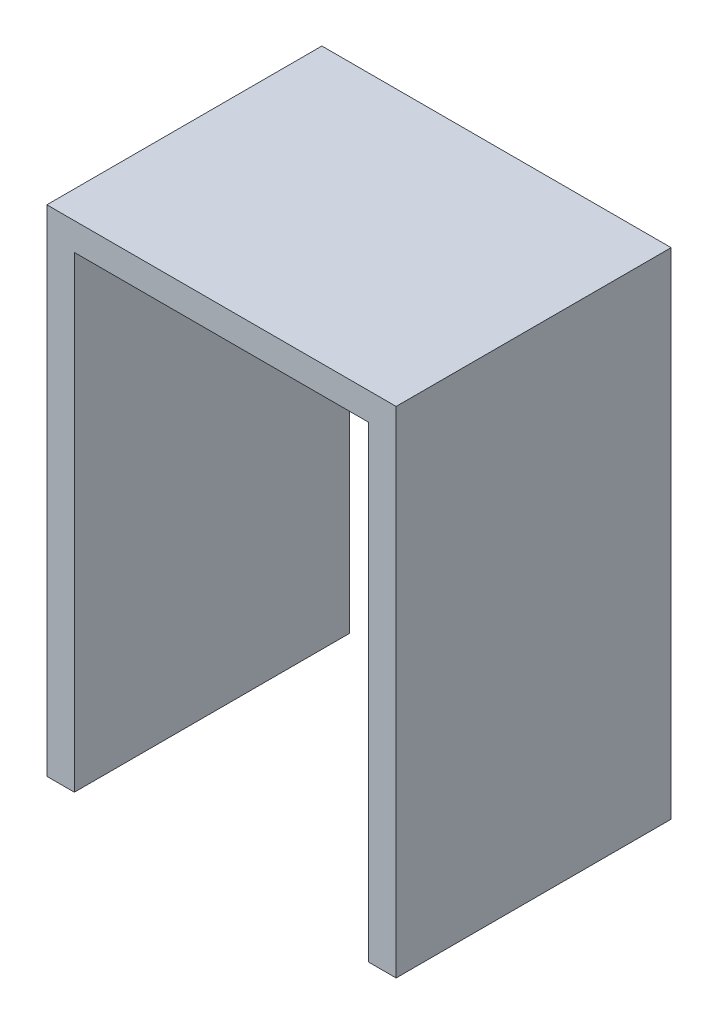
from build123d import *

# Parameters (mm, degrees)
BOSS_EXTRUDE1_DEPTH = 10


with BuildPart() as part:
    # Sketch1 → Boss-Extrude1 (new body)
    with BuildSketch(Plane.XY):
        Polygon((-2.333333333, 0), (-2.333333333, 17), (8.366666667, 17), (8.366666667, 0), (9.366666667, 0), (9.366666667, 18), (-3.333333333, 18), (-3.333333333, 0), align=None)
    extrude(amount=BOSS_EXTRUDE1_DEPTH)


solid = part.part
